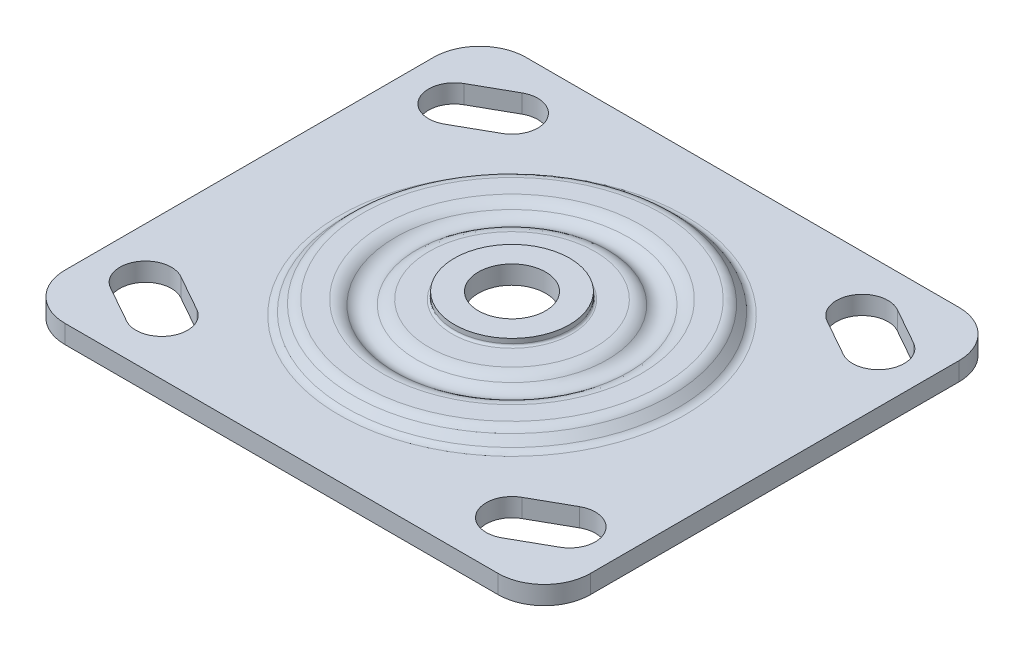
from build123d import *

# Parameters (mm, degrees)
SKETCH2_W           = 114
SKETCH2_H           = 100
SKETCH2_R           = 37.481
BOSS_EXTRUDE1_DEPTH = 4
FILLET1_R           = 10
SKETCH3_R           = 7.3
CUT_EXTRUDE1_DEPTH  = 77.297673785


with BuildPart() as part:
    # Sketch1 → Revolve1 (revolve)
    with BuildSketch(Plane.XY):
        with BuildLine():
            Line((0, 8.505), (-12.5, 8.505))
            Line((-12.5, 8.505), (-12.5, 7.5))
            ThreePointArc((-12.5, 7.5), (-12.646446609, 7.146446609), (-13, 7))
            Line((-13, 7), (-18.011, 7))
            ThreePointArc((-18.011, 7), (-19.434614481, 6.738090664), (-20.6718, 5.986660905))
            ThreePointArc((-20.6718, 5.986660905), (-23, 5.099989196), (-25.3282, 5.986660905))
            ThreePointArc((-25.3282, 5.986660905), (-26.565385519, 6.738090664), (-27.989, 7))
            Line((-27.989, 7), (-32.41, 7))
            ThreePointArc((-32.41, 7), (-33.519811535, 6.779238391), (-34.460654946, 6.150564384))
            Line((-34.460654946, 6.150564384), (-35.99604297, 4.61510855))
            ThreePointArc((-35.99604297, 4.61510855), (-36.677343371, 4.159861855), (-37.481, 4))
            Line((-37.481, 4), (-37.481, 0))
            ThreePointArc((-37.481, 0), (-35.146882545, 0.464230691), (-33.168033602, 1.786263702))
            Line((-33.168033602, 1.786263702), (-32.100521836, 2.853584942))
            ThreePointArc((-32.100521836, 2.853584942), (-31.938321103, 2.961948304), (-31.747, 3))
            Line((-31.747, 3), (-28.17591845, 3))
            ThreePointArc((-28.17591845, 3), (-28.003617351, 2.969374404), (-27.852423547, 2.881249325))
            ThreePointArc((-27.852423547, 2.881249325), (-22.909508494, 1.10053513), (-18.011, 3))
            Line((-18.011, 3), (-13.938, 3))
            ThreePointArc((-13.938, 3), (-13.019441346, 3.314145877), (-12.485631245, 4.125))
            ThreePointArc((-12.485631245, 4.125), (-12.307694545, 4.395284708), (-12.001508327, 4.5))
            Line((-12.001508327, 4.5), (0, 4.5))
            Line((0, 4.5), (0, 8.505))
        make_face()
    revolve(axis=Axis((0, 0, 0), (0, 1, 0)))

    # Sketch2 → Boss-Extrude1 (add)
    with BuildSketch(Plane(origin=(0, 0, 0), x_dir=(1, 0, 0), z_dir=(0, 1, 0))):
        Rectangle(SKETCH2_W, SKETCH2_H)
        Circle(SKETCH2_R, mode=Mode.SUBTRACT)
        with BuildLine():
            Line((-48.745462942, 38.380823008), (-40.745462942, 42.880823008))
            ThreePointArc((-40.745462942, 42.880823008), (-33.119176992, 40.745462942), (-35.254537058, 33.119176992))
            Line((-35.254537058, 33.119176992), (-43.254537058, 28.619176992))
            ThreePointArc((-43.254537058, 28.619176992), (-50.880823008, 30.754537058), (-48.745462942, 38.380823008))
        make_face(mode=Mode.SUBTRACT)
        with BuildLine():
            Line((48.745462942, -38.380823008), (40.745462942, -42.880823008))
            ThreePointArc((40.745462942, -42.880823008), (33.119176992, -40.745462942), (35.254537058, -33.119176992))
            Line((35.254537058, -33.119176992), (43.254537058, -28.619176992))
            ThreePointArc((43.254537058, -28.619176992), (50.880823008, -30.754537058), (48.745462942, -38.380823008))
        make_face(mode=Mode.SUBTRACT)
        with BuildLine():
            Line((40.745462942, 42.880823008), (48.745462942, 38.380823008))
            ThreePointArc((48.745462942, 38.380823008), (50.880823008, 30.754537058), (43.254537058, 28.619176992))
            Line((43.254537058, 28.619176992), (35.254537058, 33.119176992))
            ThreePointArc((35.254537058, 33.119176992), (33.119176992, 40.745462942), (40.745462942, 42.880823008))
        make_face(mode=Mode.SUBTRACT)
        with BuildLine():
            Line((-43.254537058, -28.619176992), (-35.254537058, -33.119176992))
            ThreePointArc((-35.254537058, -33.119176992), (-33.119176992, -40.745462942), (-40.745462942, -42.880823008))
            Line((-40.745462942, -42.880823008), (-48.745462942, -38.380823008))
            ThreePointArc((-48.745462942, -38.380823008), (-50.880823008, -30.754537058), (-43.254537058, -28.619176992))
        make_face(mode=Mode.SUBTRACT)
    extrude(amount=BOSS_EXTRUDE1_DEPTH)

    # Fillet1
    fillet1_edges = [part.edges().sort_by_distance(p)[0] for p in [
        (-57, 2, -50),
        (57, 2, -50),
        (57, 2, 50),
        (-57, 2, 50),
    ]]
    fillet(fillet1_edges, radius=FILLET1_R)

    # Sketch3 → Cut-Extrude1 (cut, through all)
    with BuildSketch(Plane(origin=(0, 8.505, 0), x_dir=(1, 0, 0), z_dir=(0, 1, 0))):
        Circle(SKETCH3_R)
    extrude(amount=-CUT_EXTRUDE1_DEPTH, mode=Mode.SUBTRACT)


solid = part.part
